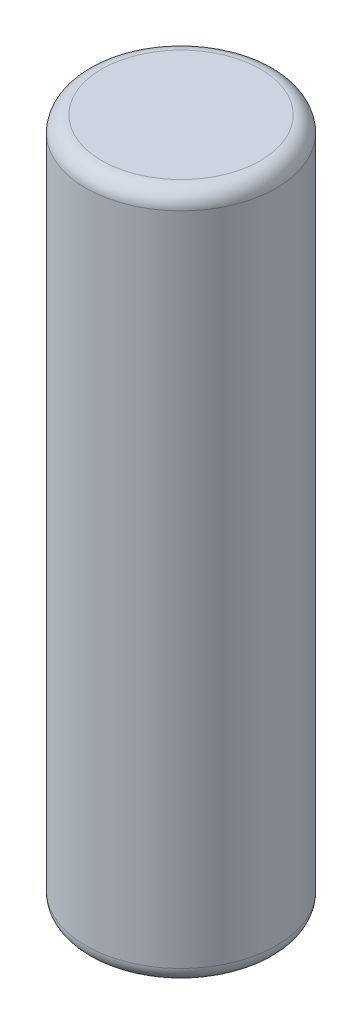
from build123d import *

# Parameters (mm, degrees)
SKETCH2_R           = 9
BOSS_EXTRUDE1_DEPTH = 65
FILLET1_R           = 1.5


with BuildPart() as part:
    # Sketch2 → Boss-Extrude1 (new body)
    with BuildSketch(Plane(origin=(0, 0, 0), x_dir=(1, 0, 0), z_dir=(0, 1, 0))):
        Circle(SKETCH2_R)
    extrude(amount=BOSS_EXTRUDE1_DEPTH)

    # Fillet1
    fillet1_edges = [part.edges().sort_by_distance(p)[0] for p in [
        (-9, 0, 0),
        (-9, 65, 0),
    ]]
    fillet(fillet1_edges, radius=FILLET1_R)


solid = part.part
